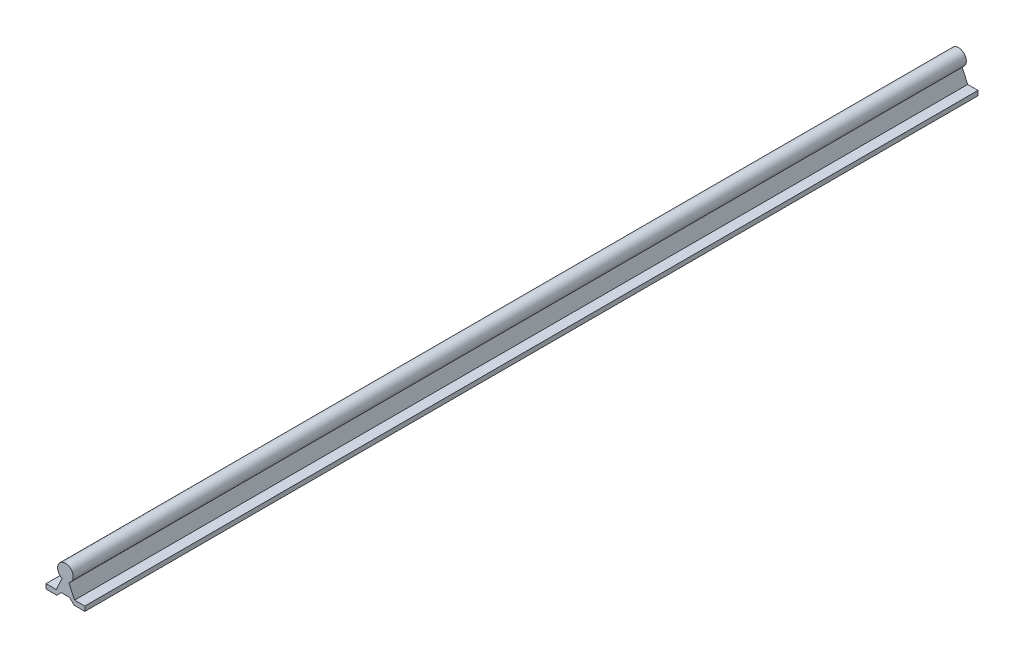
from build123d import *

# Parameters (mm, degrees)
BOSS_EXTRUDE1_DEPTH = 914.4


with BuildPart() as part:
    # Sketch1 → Boss-Extrude1 (new body)
    with BuildSketch(Plane.XY):
        with BuildLine():
            Line((3.5, 17.606252715), (9.375, 4.8))
            Line((9.375, 4.8), (19.875, 4.8))
            Line((19.875, 4.8), (19.875, 0))
            Line((19.875, 0), (8.875, 0))
            Line((8.875, 0), (4.275, 4.6))
            Line((4.275, 4.6), (-4.275, 4.6))
            Line((-4.275, 4.6), (-8.875, 0))
            Line((-8.875, 0), (-19.875, 0))
            Line((-19.875, 0), (-19.875, 4.8))
            Line((-19.875, 4.8), (-9.375, 4.8))
            Line((-9.375, 4.8), (-3.5, 17.606252715))
            ThreePointArc((-3.5, 17.606252715), (0, 32.8), (3.5, 17.606252715))
        make_face()
    extrude(amount=BOSS_EXTRUDE1_DEPTH)


solid = part.part
